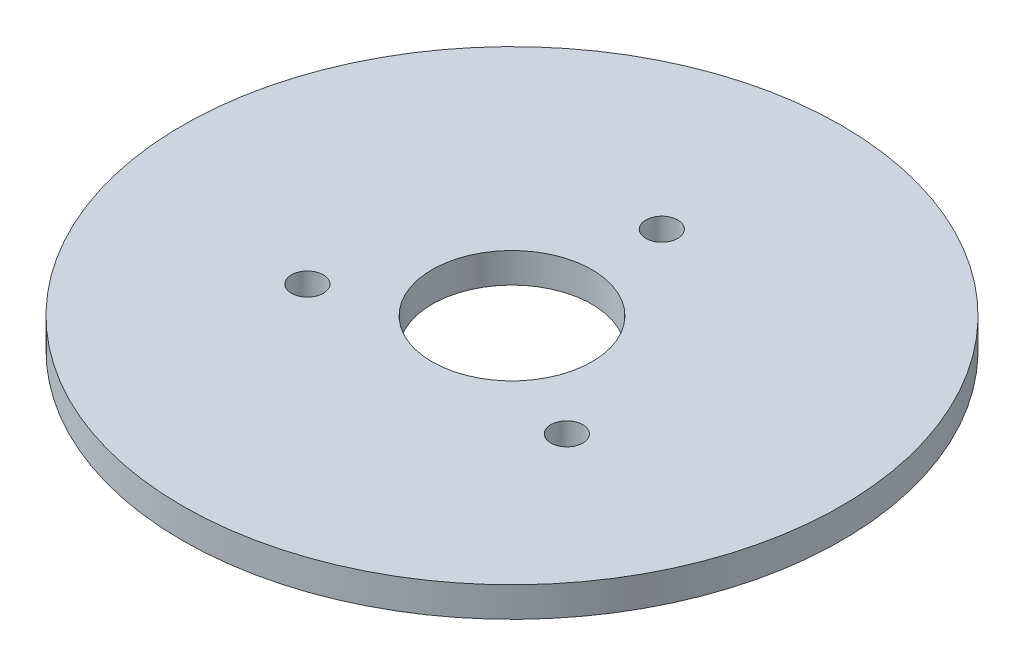
from build123d import *

# Parameters (mm, degrees)
SKETCH1_R           = 33
SKETCH1_R_2         = 1.6
SKETCH1_R_3         = 8
BOSS_EXTRUDE1_DEPTH = 3


with BuildPart() as part:
    # Sketch1 → Boss-Extrude1 (new body)
    with BuildSketch(Plane(origin=(0, 0, 0), x_dir=(1, 0, 0), z_dir=(0, 1, 0))):
        Circle(SKETCH1_R)
        with Locations((0, 15)):
            Circle(SKETCH1_R_2, mode=Mode.SUBTRACT)
        with Locations((12.990381057, -7.5)):
            Circle(SKETCH1_R_2, mode=Mode.SUBTRACT)
        with Locations((-12.990381057, -7.5)):
            Circle(SKETCH1_R_2, mode=Mode.SUBTRACT)
        Circle(SKETCH1_R_3, mode=Mode.SUBTRACT)
    extrude(amount=BOSS_EXTRUDE1_DEPTH)


solid = part.part
